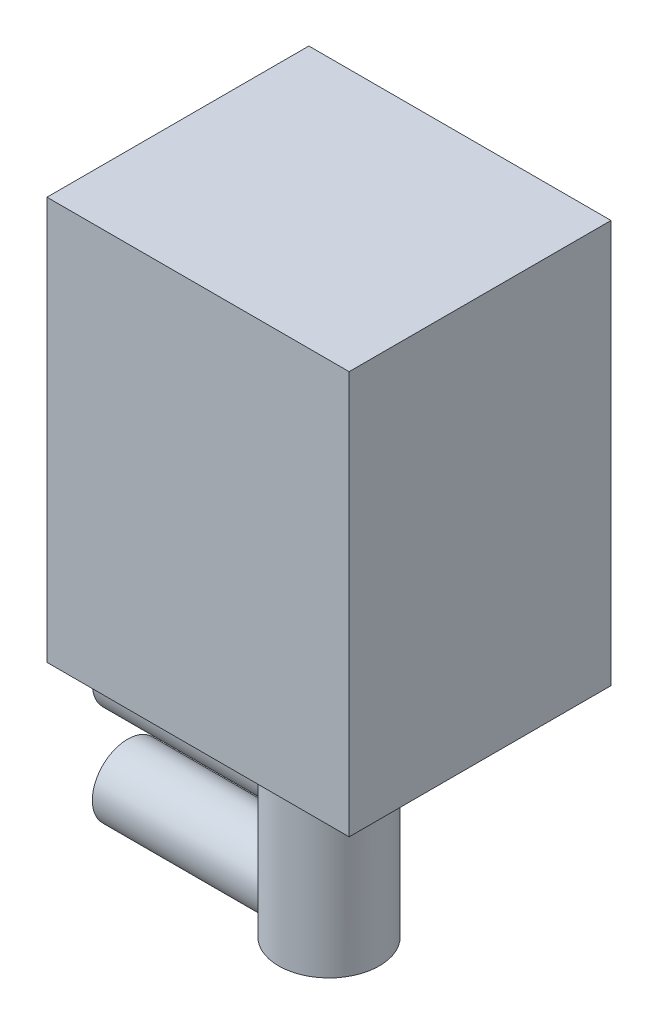
from build123d import *

# Parameters (mm, degrees)
SKETCH1_W           = 20
SKETCH1_H           = 15
BOSS_EXTRUDE1_DEPTH = 13
SKETCH2_R           = 2.5
BOSS_EXTRUDE2_DEPTH = 11.3
BOSS_EXTRUDE3_START = -7.5
SKETCH3_R           = 1.75
BOSS_EXTRUDE3_DEPTH = 10


with BuildPart() as part:
    # Sketch1 → Boss-Extrude1 (new body)
    with BuildSketch(Plane(origin=(0, 0, 0), x_dir=(0, 1, 0), z_dir=(0, 0, 1))):
        with Locations((-10, 7.5)):
            Rectangle(SKETCH1_W, SKETCH1_H)
    extrude(amount=BOSS_EXTRUDE1_DEPTH)

    # Sketch2 → Boss-Extrude2 (add)
    with BuildSketch(Plane.XZ.offset(20)):
        with Locations((-7.5, 6.5)):
            Circle(SKETCH2_R)
    extrude(amount=BOSS_EXTRUDE2_DEPTH)

    # Sketch3 → Boss-Extrude3 (add)
    with BuildSketch(Plane.YZ.offset(BOSS_EXTRUDE3_START)):
        with Locations((-29.55, 6.5)):
            Circle(SKETCH3_R)
        with Locations((-24.55, 6.5)):
            Circle(SKETCH3_R)
    extrude(amount=-BOSS_EXTRUDE3_DEPTH)


solid = part.part
